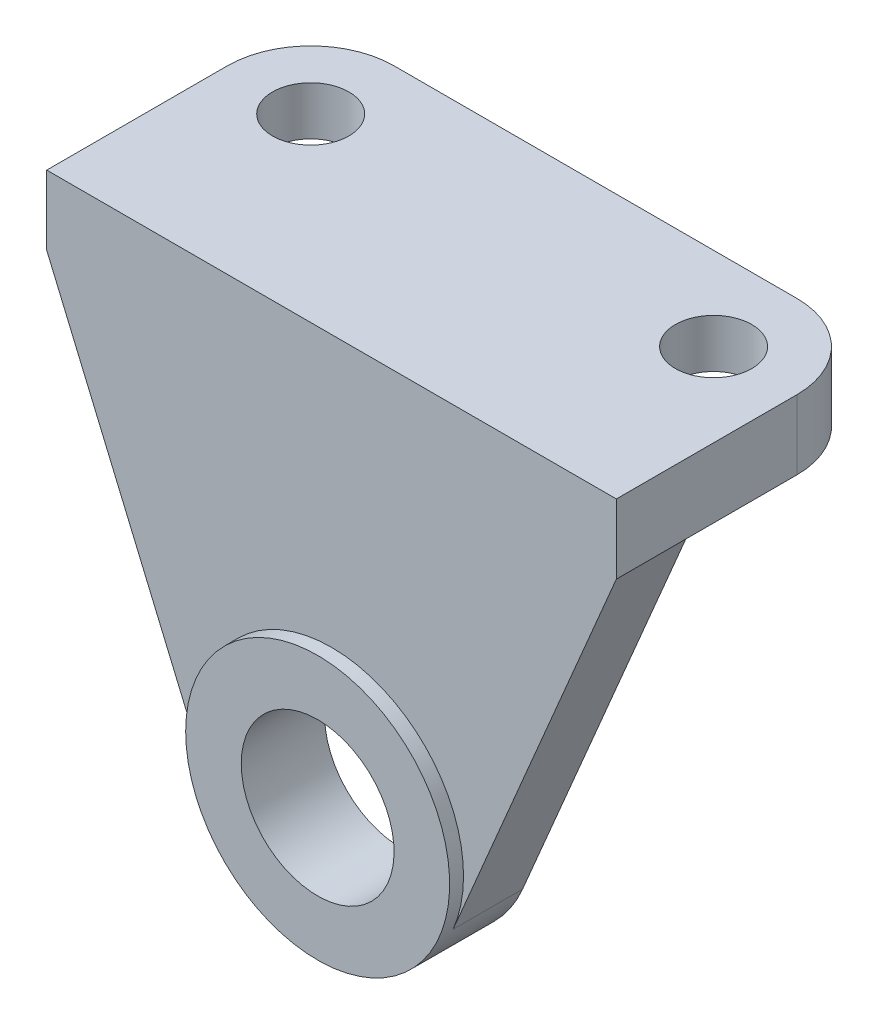
from build123d import *

# Parameters (mm, degrees)
SALIENTE_EXTRUIR1_DEPTH = 82
CORTAR_EXTRUIR1_DEPTH   = 82
CROQUIS3_R              = 11
CORTAR_EXTRUIR2_DEPTH   = 82
CORTAR_EXTRUIR4_DEPTH   = 2
REDONDEO1_R             = 12
REDONDEO2_R             = 12
CROQUIS7_R              = 10
CORTAR_EXTRUIR6_DEPTH   = 3
CROQUIS8_R              = 5.5
CORTAR_EXTRUIR7_DEPTH   = 11


with BuildPart() as part:
    # Croquis1 → Saliente-Extruir1 (new body)
    with BuildSketch(Plane(origin=(0, 0, 0), x_dir=(0, 0, -1), z_dir=(1, 0, 0))):
        Polygon((0, 0), (0, 38), (2, 38), (2, 77), (40, 77), (40, 67), (12, 67), (12, 0), align=None)
    extrude(amount=SALIENTE_EXTRUIR1_DEPTH)

    # Croquis2 → Cortar-Extruir1 (cut)
    with BuildSketch(Plane(origin=(0, 0, -12), x_dir=(-1, 0, 0), z_dir=(0, 0, -1))):
        with BuildLine():
            Line((-82, 0), (-41, 0))
            ThreePointArc((-41, 0), (-51.488696893, 3.157423269), (-58.491366878, 11.580290792))
            Line((-58.491366878, 11.580290792), (-82, 67))
            Line((-82, 67), (-82, 0))
        make_face()
        with BuildLine():
            Line((0, 0), (0, 67))
            Line((0, 67), (-23.508633122, 11.580290792))
            ThreePointArc((-23.508633122, 11.580290792), (-30.511303107, 3.157423269), (-41, 0))
            Line((-41, 0), (0, 0))
        make_face()
    extrude(amount=-CORTAR_EXTRUIR1_DEPTH, mode=Mode.SUBTRACT)

    # Croquis3 → Cortar-Extruir2 (cut)
    with BuildSketch(Plane(origin=(0, 0, -12), x_dir=(-1, 0, 0), z_dir=(0, 0, -1))):
        with Locations((-41, 19)):
            Circle(CROQUIS3_R)
    extrude(amount=-CORTAR_EXTRUIR2_DEPTH, mode=Mode.SUBTRACT)

    # Croquis5 → Cortar-Extruir4 (cut)
    with BuildSketch(Plane.XY):
        with BuildLine():
            ThreePointArc((23.508633122, 11.580290792), (25.157423269, 29.488696893), (41, 38))
            Line((41, 38), (12.301586751, 38))
            Line((12.301586751, 38), (23.508633122, 11.580290792))
        make_face()
        with BuildLine():
            ThreePointArc((41, 38), (56.842576731, 29.488696893), (58.491366878, 11.580290792))
            Line((58.491366878, 11.580290792), (69.698413249, 38))
            Line((69.698413249, 38), (41, 38))
        make_face()
    extrude(amount=-CORTAR_EXTRUIR4_DEPTH, mode=Mode.SUBTRACT)

    # Redondeo1
    redondeo1_edges = [part.edges().sort_by_distance(p)[0] for p in [
        (0, 72, -40),
    ]]
    fillet(redondeo1_edges, radius=REDONDEO1_R)

    # Redondeo2
    redondeo2_edges = [part.edges().sort_by_distance(p)[0] for p in [
        (82, 72, -40),
    ]]
    fillet(redondeo2_edges, radius=REDONDEO2_R)

    # Croquis7 → Cortar-Extruir6 (cut)
    with BuildSketch(Plane.XZ.offset(-67)):
        with Locations((12, -28)):
            Circle(CROQUIS7_R)
        with Locations((70, -28)):
            Circle(CROQUIS7_R)
    extrude(amount=-CORTAR_EXTRUIR6_DEPTH, mode=Mode.SUBTRACT)

    # Croquis8 → Cortar-Extruir7 (cut, through all)
    with BuildSketch(Plane.XZ.offset(-67)):
        with Locations((12, -28)):
            Circle(CROQUIS8_R)
        with Locations((70, -28)):
            Circle(CROQUIS8_R)
    extrude(amount=-CORTAR_EXTRUIR7_DEPTH, mode=Mode.SUBTRACT)


solid = part.part
